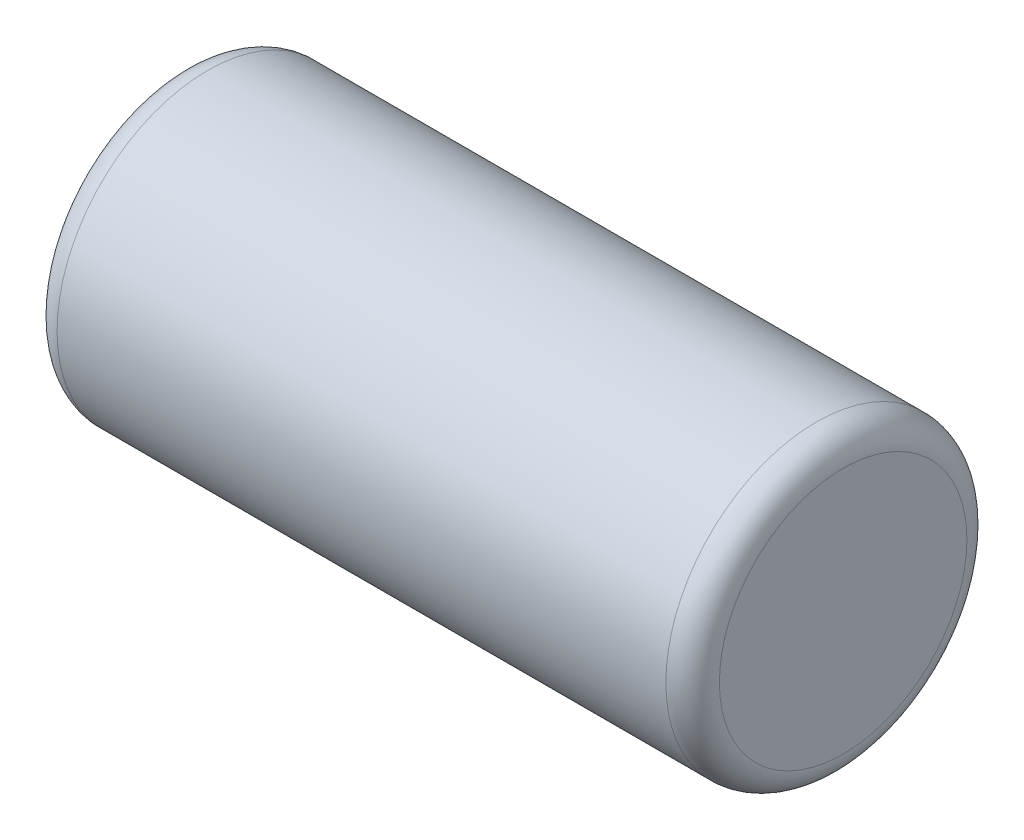
from build123d import *


with BuildPart() as part:
    # Sketch1 → Revolve1 (revolve)
    with BuildSketch(Plane.XY):
        with BuildLine():
            Line((1.35, 3.75), (1.35, 4.366666667))
            ThreePointArc((1.35, 4.366666667), (1.389052429, 4.460947571), (1.483333333, 4.5))
            Line((1.483333333, 4.5), (4.516666667, 4.5))
            ThreePointArc((4.516666667, 4.5), (4.610947571, 4.460947571), (4.65, 4.366666667))
            Line((4.65, 4.366666667), (4.65, 3.75))
            Line((4.65, 3.75), (1.35, 3.75))
        make_face()
    revolve(axis=Axis((50, 3.75, 0), (-1, 0, 0)))


solid = part.part
